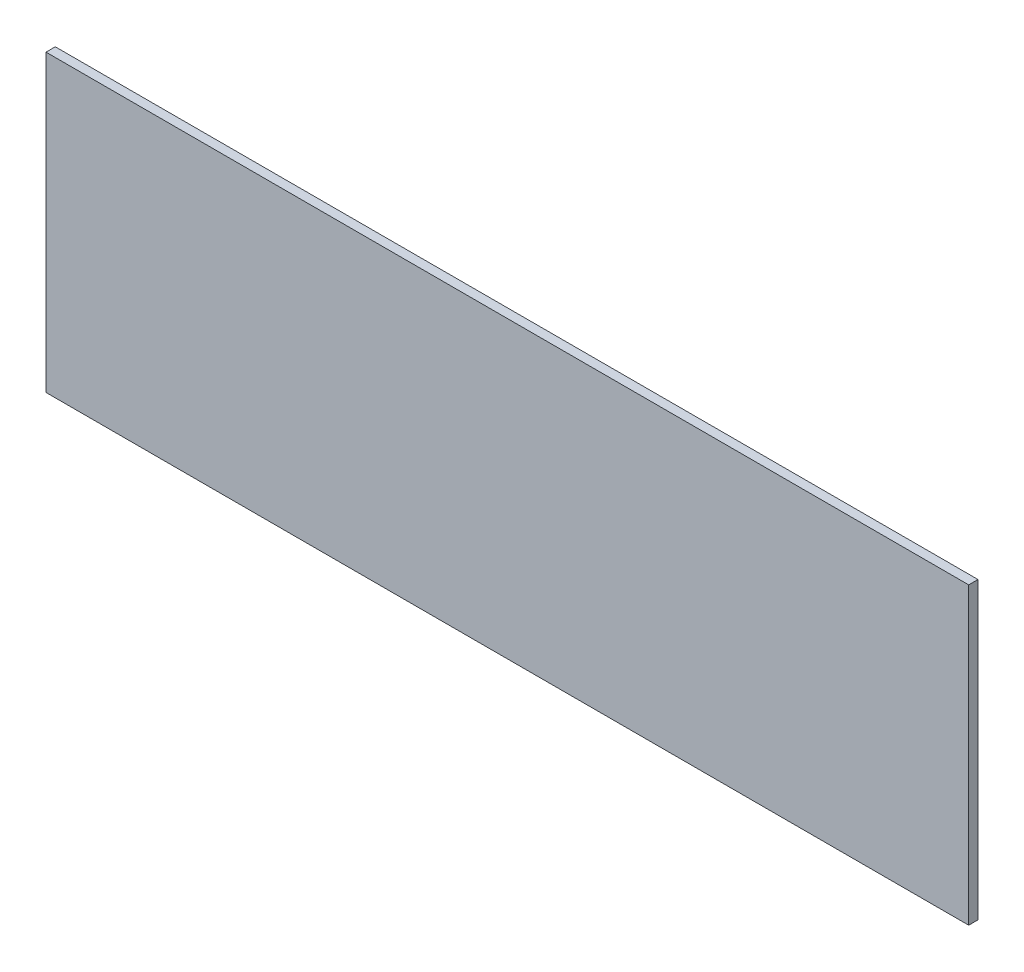
from build123d import *

# Parameters (mm, degrees)
SKETCH1_W           = 298.16
SKETCH1_H           = 95.25
BOSS_EXTRUDE1_DEPTH = 3


with BuildPart() as part:
    # Sketch1 → Boss-Extrude1 (new body)
    with BuildSketch(Plane.XY):
        with Locations((0.998, -13.335)):
            Rectangle(SKETCH1_W, SKETCH1_H)
    extrude(amount=BOSS_EXTRUDE1_DEPTH)


solid = part.part
